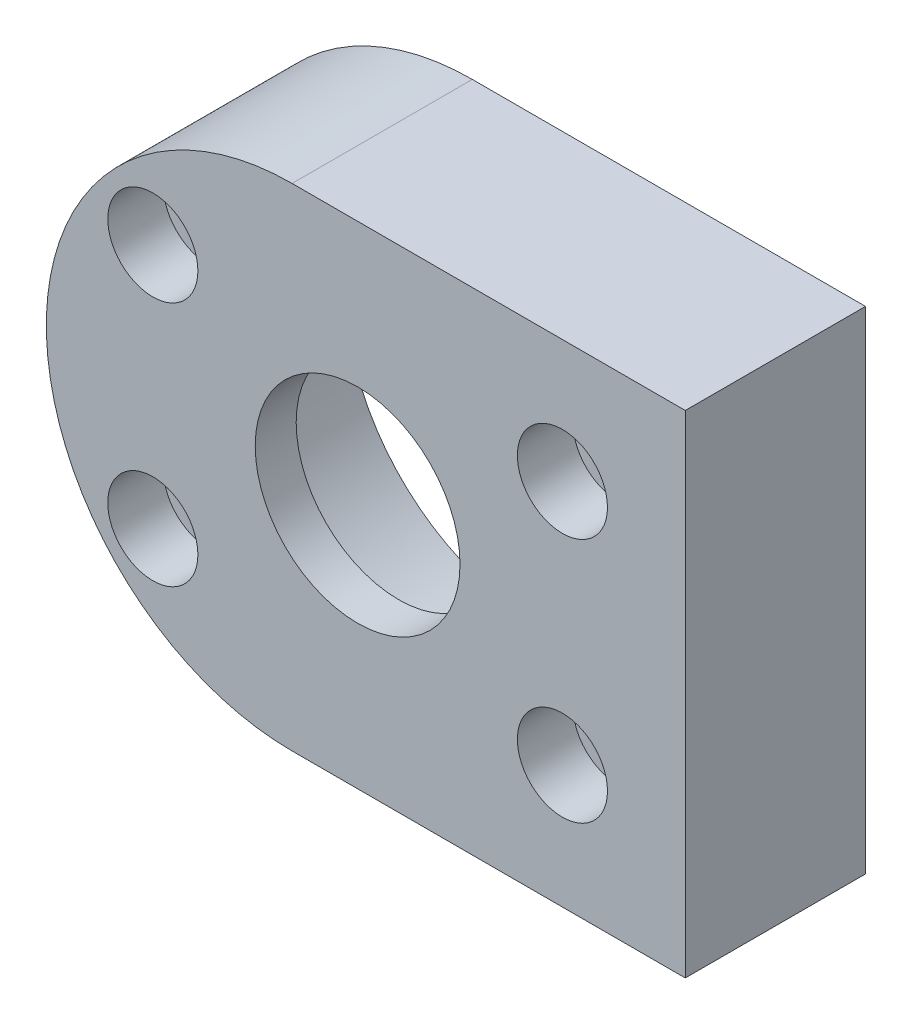
from build123d import *

# Parameters (mm, degrees)
SKETCH_1_R                = 12.5
EXTRUDE_1_DEPTH           = 22
HOLE_WIZARD_1_D           = 6.6
HOLE_WIZARD_1_CBORE_D     = 11
HOLE_WIZARD_1_CBORE_DEPTH = 6.8
SKETCH_5_R                = 23.5
CUT_EXTRUDE_1_DEPTH       = 13
SKETCH_6_R                = 20
CUT_EXTRUDE_2_DEPTH       = 4


with BuildPart() as part:
    # 草图1 → 凸台-拉伸1 (new body)
    with BuildSketch(Plane.XY):
        with BuildLine():
            Line((-8, 30), (40, 30))
            Line((40, 30), (40, -30))
            Line((40, -30), (-8, -30))
            ThreePointArc((-8, -30), (-38, 0), (-8, 30))
        make_face()
        Circle(SKETCH_1_R, mode=Mode.SUBTRACT)
    extrude(amount=EXTRUDE_1_DEPTH)

    # 打孔尺寸(%根据)内六角圆柱头螺钉的类型1 (through all)
    with Locations(Plane(origin=(-25, 15, 22), x_dir=(1, 0, 0), z_dir=(0, 0, 1))):
        with Locations((0, 0), (0, -30), (50, 0), (50, -30)):
            CounterBoreHole(HOLE_WIZARD_1_D / 2, HOLE_WIZARD_1_CBORE_D / 2, HOLE_WIZARD_1_CBORE_DEPTH)

    # 草图5 → 切除-拉伸1 (cut)
    with BuildSketch(Plane(origin=(0, 0, 0), x_dir=(-1, 0, 0), z_dir=(0, 0, -1))):
        Circle(SKETCH_5_R)
    extrude(amount=-CUT_EXTRUDE_1_DEPTH, mode=Mode.SUBTRACT)

    # 草图6 → 切除-拉伸2 (cut)
    with BuildSketch(Plane(origin=(0, 0, 13), x_dir=(-1, 0, 0), z_dir=(0, 0, -1))):
        Circle(SKETCH_6_R)
    extrude(amount=-CUT_EXTRUDE_2_DEPTH, mode=Mode.SUBTRACT)


solid = part.part
